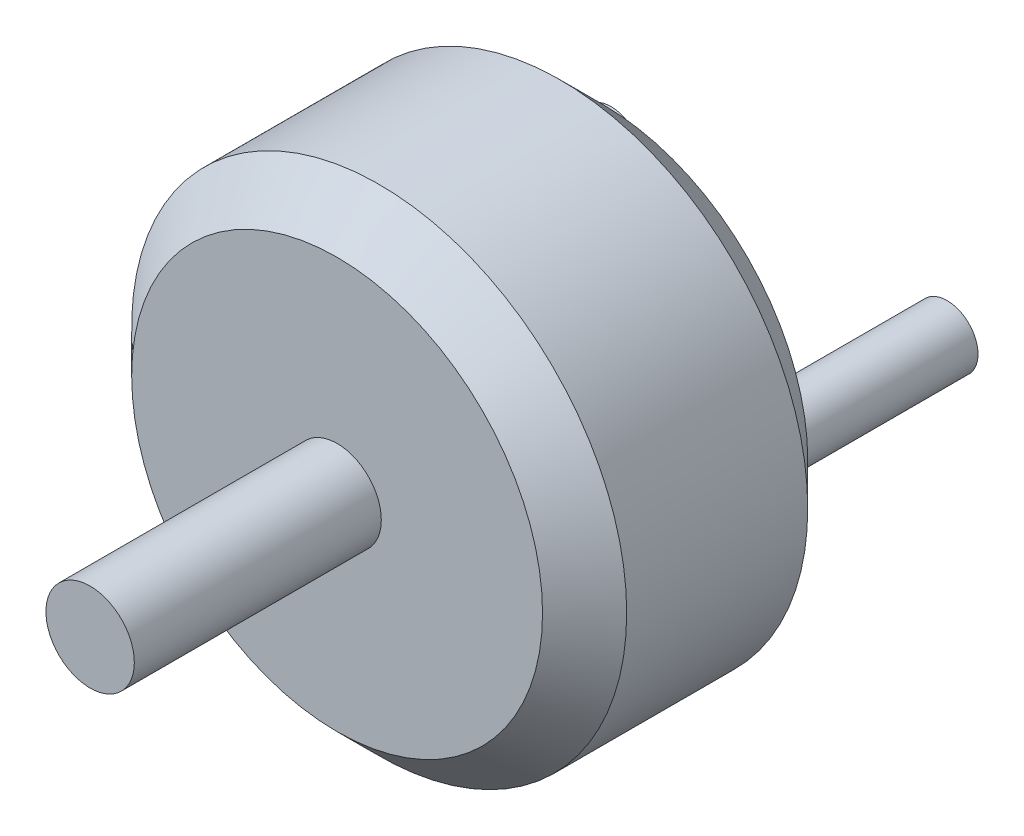
from build123d import *

# Parameters (mm, degrees)
SKETCH1_R           = 14
BOSS_EXTRUDE1_DEPTH = 15
CHAMFER1_SIZE       = 2.38
SKETCH3_R           = 2.5
BOSS_EXTRUDE2_DEPTH = 13.97
SKETCH5_R           = 1.75
BOSS_EXTRUDE4_DEPTH = 10


with BuildPart() as part:
    # Sketch1 → Boss-Extrude1 (new body)
    with BuildSketch(Plane.XY):
        Circle(SKETCH1_R)
    extrude(amount=BOSS_EXTRUDE1_DEPTH)

    # Chamfer1
    chamfer1_edges = [part.edges().sort_by_distance(p)[0] for p in [
        (-14, 0, 0),
        (-14, 0, 15),
    ]]
    chamfer(chamfer1_edges, length=CHAMFER1_SIZE)

    # Sketch3 → Boss-Extrude2 (add)
    with BuildSketch(Plane.XY.offset(15)):
        Circle(SKETCH3_R)
    extrude(amount=BOSS_EXTRUDE2_DEPTH)

    # Sketch5 → Boss-Extrude4 (add)
    with BuildSketch(Plane(origin=(0, 0, 0), x_dir=(-1, 0, 0), z_dir=(0, 0, -1))):
        with Locations((-9.5, 0)):
            Circle(SKETCH5_R)
        with Locations((9.5, 0)):
            Circle(SKETCH5_R)
    extrude(amount=BOSS_EXTRUDE4_DEPTH)


solid = part.part
